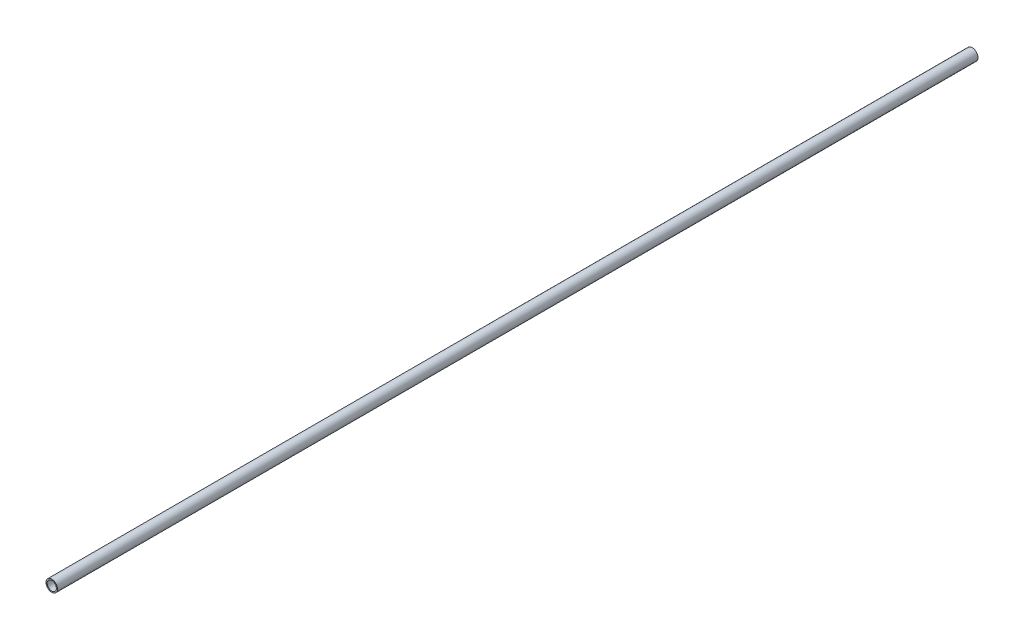
from build123d import *

# Parameters (mm, degrees)
SKETCH1_R           = 5
SKETCH1_R_2         = 4
BOSS_EXTRUDE1_DEPTH = 800


with BuildPart() as part:
    # Sketch1 → Boss-Extrude1 (new body)
    with BuildSketch(Plane.XY):
        Circle(SKETCH1_R)
        Circle(SKETCH1_R_2, mode=Mode.SUBTRACT)
    extrude(amount=BOSS_EXTRUDE1_DEPTH)


solid = part.part
